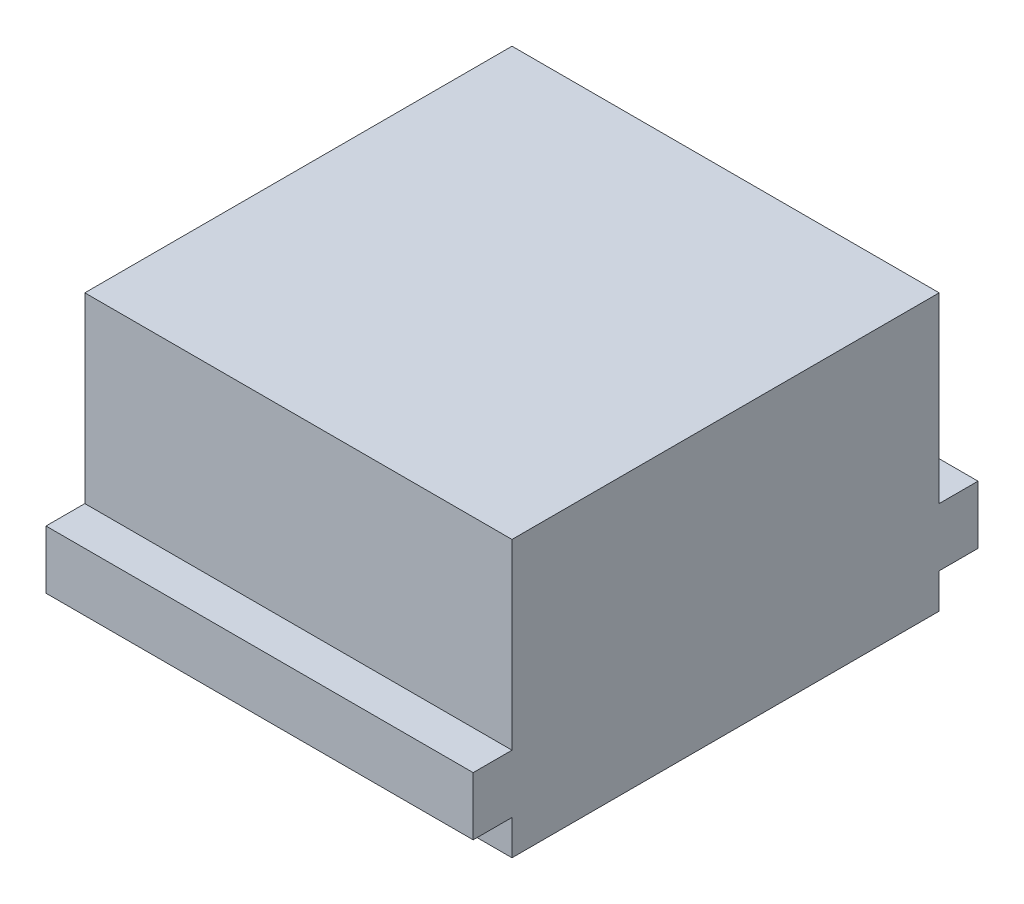
from build123d import *

# Parameters (mm, degrees)
SKETCH_1_W      = 110
SKETCH_1_H      = 110
EXTRUDE_1_DEPTH = 71
SKETCH_2_W      = 110
SKETCH_2_H      = 15
EXTRUDE_3_DEPTH = 10
SKETCH_3_W      = 110
SKETCH_3_H      = 15
EXTRUDE_4_DEPTH = 10


with BuildPart() as part:
    # 草图1 → 凸台-拉伸1 (new body)
    with BuildSketch(Plane(origin=(0, 0, 0), x_dir=(1, 0, 0), z_dir=(0, 1, 0))):
        with Locations((55, 55)):
            Rectangle(SKETCH_1_W, SKETCH_1_H)
    extrude(amount=EXTRUDE_1_DEPTH)

    # 草图2 → 凸台-拉伸3 (add)
    with BuildSketch(Plane.XY):
        with Locations((55, 16.5)):
            Rectangle(SKETCH_2_W, SKETCH_2_H)
    extrude(amount=EXTRUDE_3_DEPTH)

    # 草图3 → 凸台-拉伸4 (add)
    with BuildSketch(Plane(origin=(0, 0, -110), x_dir=(-1, 0, 0), z_dir=(0, 0, -1))):
        with Locations((-55, 16.5)):
            Rectangle(SKETCH_3_W, SKETCH_3_H)
    extrude(amount=EXTRUDE_4_DEPTH)


solid = part.part
